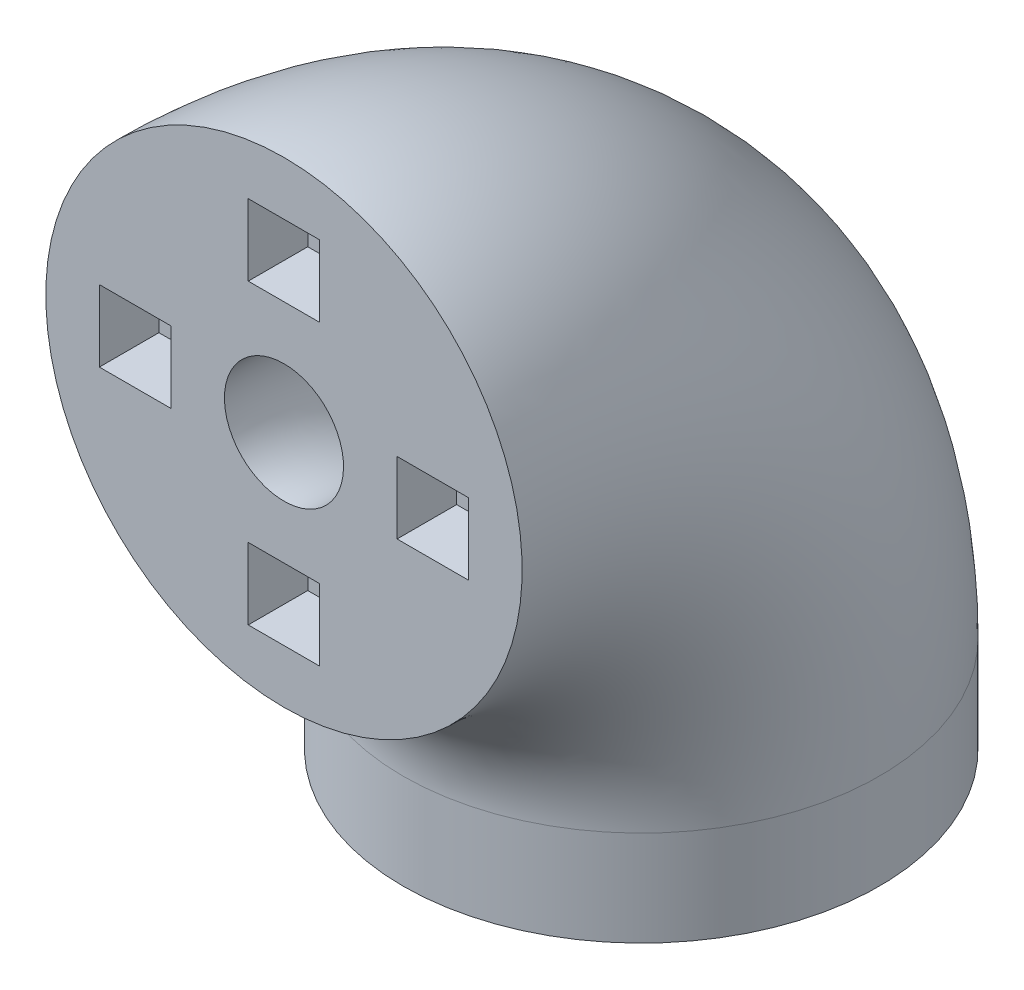
from build123d import *

# Parameters (mm, degrees)
SKETCH3_R           = 20
SKETCH3_R_2         = 5
SKETCH6_R           = 20
SKETCH6_R_2         = 5
BOSS_EXTRUDE1_DEPTH = 8
SKETCH10_W          = 6
SKETCH10_H          = 6
CUT_EXTRUDE5_DEPTH  = 5


with BuildPart() as part:
    # Sweep1: sweep along a path in Sketch2
    with BuildLine(Plane(origin=(0, 0, 0), x_dir=(0, 0, -1), z_dir=(1, 0, 0))) as sweep1_path:
        ThreePointArc((30, 0), (21.213203436, 21.213203436), (0, 30))
    # Sketch3 → Sweep1 (sweep)
    with BuildSketch(Plane(origin=(0, 0, 0), x_dir=(1, 0, 0), z_dir=(0, 1, 0))):
        with Locations((0, 30)):
            Circle(SKETCH3_R)
        with Locations((0, 30)):
            Circle(SKETCH3_R_2, mode=Mode.SUBTRACT)
    sweep(path=sweep1_path.line)

    # Sketch6 → Boss-Extrude1 (add)
    with BuildSketch(Plane.XZ):
        with Locations((0, -30)):
            Circle(SKETCH6_R)
        with Locations((0, -30)):
            Circle(SKETCH6_R_2, mode=Mode.SUBTRACT)
    extrude(amount=BOSS_EXTRUDE1_DEPTH)

    # Sketch10 → Cut-Extrude5 (cut)
    with BuildSketch(Plane.XY):
        with Locations((0, 42.5)):
            Rectangle(SKETCH10_W, SKETCH10_H)
        with Locations((-12.5, 30)):
            Rectangle(SKETCH10_W, SKETCH10_H)
        with Locations((12.5, 30)):
            Rectangle(SKETCH10_W, SKETCH10_H)
        with Locations((0, 17.5)):
            Rectangle(SKETCH10_W, SKETCH10_H)
    extrude(amount=-CUT_EXTRUDE5_DEPTH, mode=Mode.SUBTRACT)


solid = part.part
